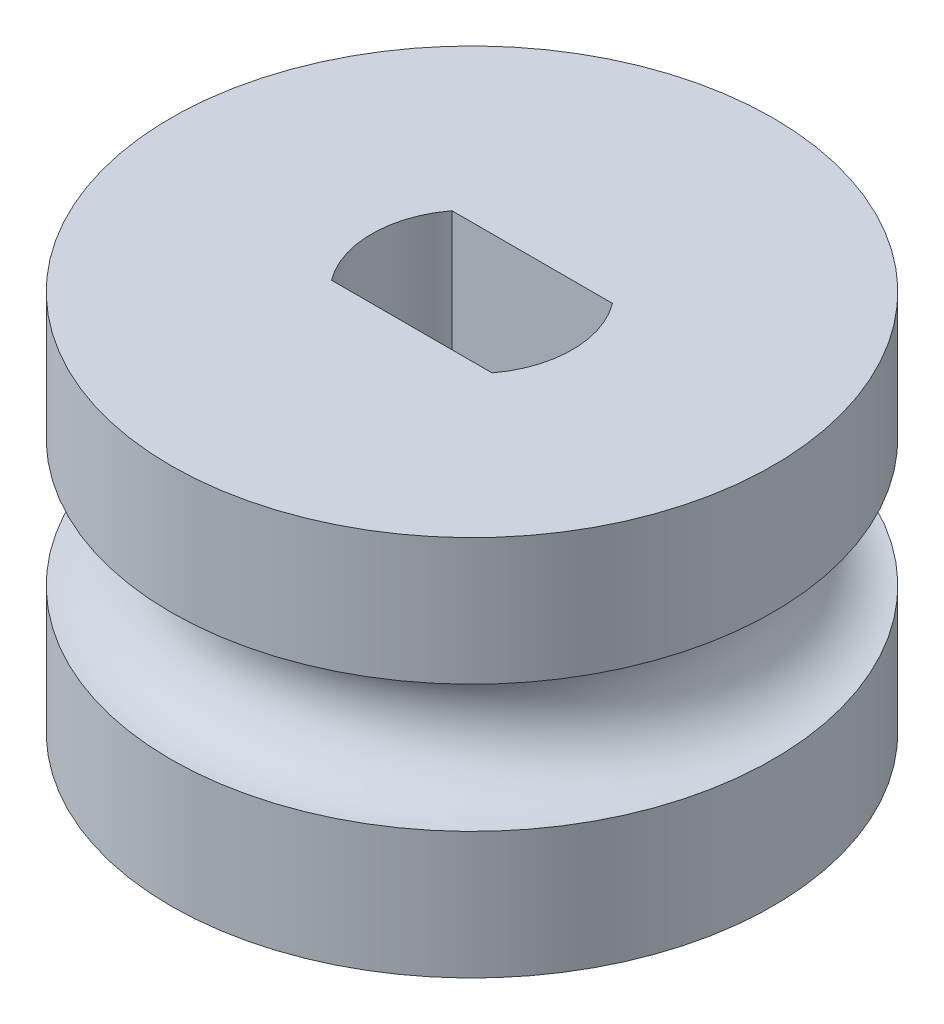
from build123d import *

# Parameters (mm, degrees)
SKETCH1_R           = 7.5
BOSS_EXTRUDE1_DEPTH = 9.5
SKETCH2_R           = 1.5875


with BuildPart() as part:
    # Sketch1 → Boss-Extrude1 (new body)
    with BuildSketch(Plane(origin=(0, 0, 0), x_dir=(1, 0, 0), z_dir=(0, 1, 0))):
        Circle(SKETCH1_R)
        with BuildLine():
            Line((-2, 1.5), (2, 1.5))
            ThreePointArc((2, 1.5), (2.5, 0), (2, -1.5))
            Line((2, -1.5), (-2, -1.5))
            ThreePointArc((-2, -1.5), (-2.5, 0), (-2, 1.5))
        make_face(mode=Mode.SUBTRACT)
    extrude(amount=BOSS_EXTRUDE1_DEPTH)

    # Sketch2 → Cut-Revolve1 (revolve, cut)
    with BuildSketch(Plane.XY):
        with Locations((7.5, 4.75)):
            Circle(SKETCH2_R)
    revolve(axis=Axis((0, 9.5, 0), (0, -1, 0)), mode=Mode.SUBTRACT)


solid = part.part
